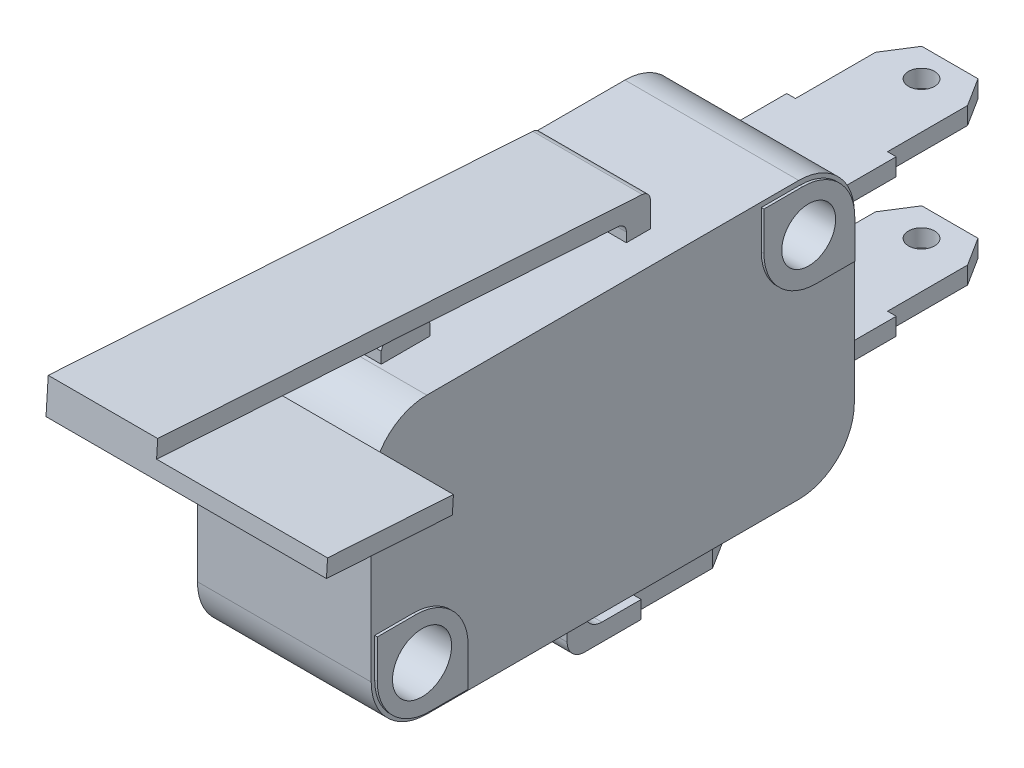
from build123d import *

# Parameters (mm, degrees)
BLOCOBASE_DEPTH           = 5
SKFIXACAO_R               = 1.7
SKFIXACAO_R_2             = 1.55
FIXACAO_DEPTH             = 5.15
RESSALTOFIXACAO_DEPTH     = 0.15
BOTAO_DEPTH               = 2.15
SKETCH5_W                 = 6.3
SKETCH5_H                 = 1
BASECONECTORNONC_DEPTH    = 10.5
SKDESENHOCONECTORNONC_R   = 0.75
DESENHOCONECTORNONC_DEPTH = 20.5
BASECONECTORCOM_DEPTH     = 3.15
SKDESENHOCONECTORCOM_R    = 0.75
DESENHOCONECTORCOM_DEPTH  = 1
BASECONTATO_DEPTH         = 3.15
SKAPOIOROLO_R             = 0.7
APOIOROLO_DEPTH           = 1
SKROLO_R                  = 2.5
ROLO_DEPTH                = 4.3
SKETCH6_W                 = 15.037683952
SKETCH6_H                 = 10.848275608
CUT_EXTRUDE1_DEPTH        = 10
SKETCH7_W                 = 16.137668404
SKETCH7_H                 = 7.258990492
BOSS_EXTRUDE1_DEPTH       = 1


with BuildPart() as part:
    # skBlocoBase → BlocoBase (new body, symmetric)
    with BuildSketch(Plane(origin=(0, 0, 0), x_dir=(0, 0, -1), z_dir=(1, 0, 0))):
        with BuildLine():
            Line((-10.7, 7.95), (10.7, 7.95))
            ThreePointArc((10.7, 7.95), (12.9627417, 7.0127417), (13.9, 4.75))
            Line((13.9, 4.75), (13.9, -4.75))
            ThreePointArc((13.9, -4.75), (12.9627417, -7.0127417), (10.7, -7.95))
            Line((10.7, -7.95), (-10.7, -7.95))
            ThreePointArc((-10.7, -7.95), (-12.9627417, -7.0127417), (-13.9, -4.75))
            Line((-13.9, -4.75), (-13.9, 4.75))
            ThreePointArc((-13.9, 4.75), (-12.9627417, 7.0127417), (-10.7, 7.95))
        make_face()
    extrude(amount=BLOCOBASE_DEPTH, both=True)

    # skFixacao → Fixacao (cut, symmetric)
    with BuildSketch(Plane(origin=(0, 0, 0), x_dir=(0, 0, -1), z_dir=(1, 0, 0))):
        with Locations((-11.125, -5.1)):
            Circle(SKFIXACAO_R)
        with Locations((11.125, 5.1)):
            Circle(SKFIXACAO_R_2)
    extrude(amount=FIXACAO_DEPTH, both=True, mode=Mode.SUBTRACT)

    # skRessaltoFixacao → RessaltoFixacao (add)
    with BuildSketch(Plane(origin=(5, 0, 0), x_dir=(0, 0, -1), z_dir=(1, 0, 0))):
        with BuildLine():
            ThreePointArc((-8.475, -5.525), (-9.353679656, -3.403679656), (-11.475, -2.525))
            Line((-11.475, -2.525), (-13.7, -2.525))
            Line((-13.7, -2.525), (-13.7, -4.75))
            ThreePointArc((-13.7, -4.75), (-12.821320344, -6.871320344), (-10.7, -7.75))
            Line((-10.7, -7.75), (-8.475, -7.75))
            Line((-8.475, -7.75), (-8.475, -5.525))
        make_face()
        with BuildLine():
            ThreePointArc((-9.789845005, -6.152312282), (-10.474438165, -6.670595205), (-11.325, -6.788194302))
            ThreePointArc((-11.325, -6.788194302), (-11.775561835, -3.529404795), (-9.789845005, -6.152312282))
        make_face(mode=Mode.SUBTRACT)
        with BuildLine():
            ThreePointArc((13.775, 4.675), (12.896320344, 6.796320344), (10.775, 7.675))
            Line((10.775, 7.675), (8.55, 7.675))
            Line((8.55, 7.675), (8.55, 5.45))
            ThreePointArc((8.55, 5.45), (9.428679656, 3.328679656), (11.55, 2.45))
            Line((11.55, 2.45), (13.775, 2.45))
            Line((13.775, 2.45), (13.775, 4.675))
        make_face()
        with BuildLine():
            ThreePointArc((12.353274612, 4.1545681), (11.71815932, 3.667986725), (10.925, 3.562957385))
            ThreePointArc((10.925, 3.562957385), (10.53184068, 6.532013275), (12.353274612, 4.1545681))
        make_face(mode=Mode.SUBTRACT)
    ressaltofixacao = extrude(amount=RESSALTOFIXACAO_DEPTH)

    # MirrorRessaltoFixacao: RessaltoFixacao across plane
    add(ressaltofixacao.mirror(Plane(origin=(0, 0, 0), x_dir=(0, 0, 1), z_dir=(1, 0, 0))))

    # skBotao → Botao (add, symmetric)
    with BuildSketch(Plane(origin=(0, 0, 0), x_dir=(0, 0, -1), z_dir=(1, 0, 0))):
        with BuildLine():
            Line((-10.475, 7.95), (-10.475, 8.6))
            ThreePointArc((-10.475, 8.6), (-9.075, 9.6), (-7.675, 8.6))
            Line((-7.675, 8.6), (-7.675, 7.95))
            Line((-7.675, 7.95), (-10.475, 7.95))
        make_face()
    extrude(amount=BOTAO_DEPTH, both=True)

    # Sketch5 → BaseConectorNONC (add)
    with BuildSketch(Plane(origin=(0, 0, -13.9), x_dir=(-1, 0, 0), z_dir=(0, 0, -1))):
        with Locations((0, -3.975)):
            Rectangle(SKETCH5_W, SKETCH5_H)
        with Locations((0, 3.975)):
            Rectangle(SKETCH5_W, SKETCH5_H)
    extrude(amount=BASECONECTORNONC_DEPTH)

    # skDesenhoConectorNONC → DesenhoConectorNONC (cut)
    with BuildSketch(Plane.XZ.offset(4.475)):
        Polygon((2.65, -22.767142952), (1.616967042, -24.4), (3.15, -24.4), (3.15, -18.161236833), (2.65, -18.161236833), align=None)
        Polygon((-3.15, -24.4), (-1.616967042, -24.4), (-2.65, -22.767142952), (-2.65, -18.161236833), (-3.15, -18.161236833), align=None)
        with Locations((0, -22.767142952)):
            Circle(SKDESENHOCONECTORNONC_R)
    extrude(amount=-DESENHOCONECTORNONC_DEPTH, mode=Mode.SUBTRACT)

    # skBaseConectorCOM → BaseConectorCOM (add, symmetric)
    with BuildSketch(Plane(origin=(0, 0, 0), x_dir=(0, 0, -1), z_dir=(1, 0, 0))):
        with BuildLine():
            Line((9.725, -11.25), (0.225, -11.25))
            ThreePointArc((0.225, -11.25), (-0.482106781, -10.957106781), (-0.775, -10.25))
            Line((-0.775, -10.25), (-0.775, -7.95))
            Line((-0.775, -7.95), (0.225, -7.95))
            Line((0.225, -7.95), (0.225, -9.25))
            ThreePointArc((0.225, -9.25), (0.517893219, -9.957106781), (1.225, -10.25))
            Line((1.225, -10.25), (9.725, -10.25))
            Line((9.725, -10.25), (9.725, -11.25))
        make_face()
    extrude(amount=BASECONECTORCOM_DEPTH, both=True)

    # skDesenhoConectorCOM → DesenhoConectorCOM (cut)
    with BuildSketch(Plane.XZ.offset(11.25)):
        Polygon((2.65, -8.092142952), (1.616967042, -9.725), (3.15, -9.725), (3.15, -3.486236833), (2.65, -3.486236833), align=None)
        Polygon((-3.15, -9.725), (-1.616967042, -9.725), (-2.65, -8.092142952), (-2.65, -3.486236833), (-3.15, -3.486236833), align=None)
        with Locations((0, -8.092142952)):
            Circle(SKDESENHOCONECTORCOM_R)
    extrude(amount=-DESENHOCONECTORCOM_DEPTH, mode=Mode.SUBTRACT)

    # skBaseContato → BaseContato (add, symmetric)
    with BuildSketch(Plane(origin=(0, 0, 0), x_dir=(0, 0, -1), z_dir=(1, 0, 0))):
        with BuildLine():
            Line((2.63302332, 7.95), (2.63302332, 8.486635004))
            ThreePointArc((2.63302332, 8.486635004), (2.497665983, 8.828739854), (2.164880406, 8.985619098))
            Line((2.164880406, 8.985619098), (-24.4, 10.681624431))
            Line((-24.4, 10.681624431), (-24.336285828, 11.679592619))
            Line((-24.336285828, 11.679592619), (3.545575005, 9.899506131))
            ThreePointArc((3.545575005, 9.899506131), (3.878360582, 9.742626887), (4.013717919, 9.400522037))
            Line((4.013717919, 9.400522037), (4.013717919, 7.95))
            Line((4.013717919, 7.95), (2.63302332, 7.95))
        make_face()
    extrude(amount=BASECONTATO_DEPTH, both=True)

    # skApoioRolo → ApoioRolo (add)
    with BuildSketch(Plane(origin=(3.15, 0, 0), x_dir=(0, 0, -1), z_dir=(1, 0, 0))):
        with BuildLine():
            ThreePointArc((-21.354211514, 14.486814776), (-22.754211514, 15.886814776), (-24.154211514, 14.486814776))
            Line((-24.154211514, 14.486814776), (-24.336285828, 11.679592619))
            Line((-24.336285828, 11.679592619), (-22.939130364, 11.590392778))
            Line((-22.939130364, 11.590392778), (-21.541974901, 11.501192936))
            Line((-21.541974901, 11.501192936), (-21.365242034, 14.3114187))
            Line((-21.365242034, 14.3114187), (-21.354211514, 14.486814776))
        make_face()
        with Locations((-22.754211514, 14.486814776)):
            Circle(SKAPOIOROLO_R, mode=Mode.SUBTRACT)
    apoiorolo = extrude(amount=-APOIOROLO_DEPTH)

    # MirrorApoioRolo: ApoioRolo across plane
    add(apoiorolo.mirror(Plane(origin=(0, 0, 0), x_dir=(0, 0, 1), z_dir=(1, 0, 0))))

    # skRolo → Rolo (add)
    with BuildSketch(Plane.ZY.offset(-2.15)):
        with Locations((22.754211514, 14.486814776)):
            Circle(SKROLO_R)
    extrude(amount=ROLO_DEPTH)

    # Sketch6 → Cut-Extrude1 (cut)
    with BuildSketch(Plane(origin=(0, 10.084763511, -0.643850544), x_dir=(1, 0, 0), z_dir=(0, 0.997968188, -0.063714172))):
        with Locations((-4.368841976, -23.671158356)):
            Rectangle(SKETCH6_W, SKETCH6_H)
    extrude(amount=CUT_EXTRUDE1_DEPTH, mode=Mode.SUBTRACT)

    # Sketch7 → Boss-Extrude1 (add)
    with BuildSketch(Plane(origin=(0, 9.086795323, -0.580136372), x_dir=(1, 0, 0), z_dir=(0, -0.997968188, 0.063714172))):
        with Locations((4.918834202, 21.401499401)):
            Rectangle(SKETCH7_W, SKETCH7_H)
    extrude(amount=BOSS_EXTRUDE1_DEPTH)


solid = part.part
